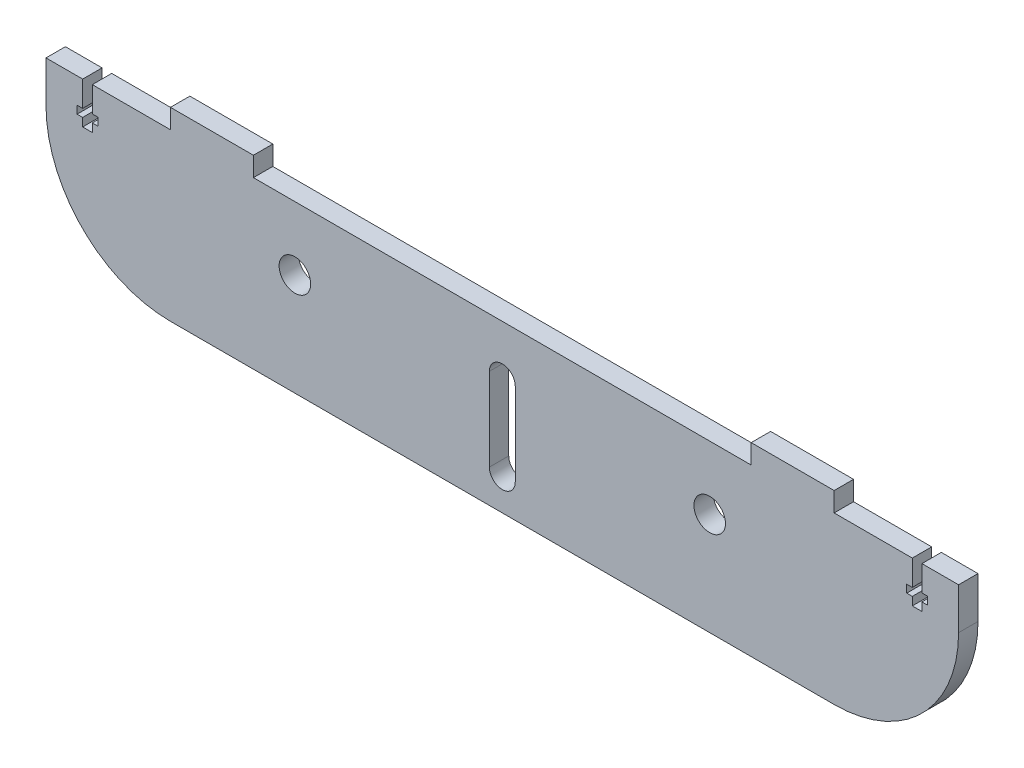
from build123d import *

# Parameters (mm, degrees)
BOSS_EXTRUDE1_DEPTH = 5.9436
CUT_EXTRUDE1_DEPTH  = 6.35
SKETCH3_R           = 4.826
CUT_EXTRUDE2_DEPTH  = 6.9436
CUT_EXTRUDE3_DEPTH  = 6.9436


with BuildPart() as part:
    # Sketch1 → Boss-Extrude1 (new body)
    with BuildSketch(Plane.XY):
        Polygon((-101.6, 25.4), (-101.6, 31.3436), (-76.2, 31.3436), (-76.2, 25.4), (76.2, 25.4), (76.2, 31.3436), (101.6, 31.3436), (101.6, 25.4), (139.7, 25.4), (139.7, -25.4), (-139.7, -25.4), (-139.7, 25.4), align=None)
    extrude(amount=BOSS_EXTRUDE1_DEPTH)

    # Sketch2 → Cut-Extrude1 (cut)
    with BuildSketch(Plane.XY.offset(5.9436)):
        Polygon((-128.4732, 25.4), (-128.4732, 17.62125), (-130.175, 17.62125), (-130.175, 15.24), (-128.4732, 15.24), (-128.4732, 12.7), (-125.5268, 12.7), (-125.5268, 15.24), (-123.825, 15.24), (-123.825, 17.62125), (-125.5268, 17.62125), (-125.5268, 25.4), align=None)
        Polygon((125.5268, 17.62125), (125.5268, 25.4), (128.4732, 25.4), (128.4732, 17.62125), (130.175, 17.62125), (130.175, 15.24), (128.4732, 15.24), (128.4732, 12.7), (125.5268, 12.7), (125.5268, 15.24), (123.825, 15.24), (123.825, 17.62125), align=None)
    extrude(amount=-CUT_EXTRUDE1_DEPTH, mode=Mode.SUBTRACT)

    # Sketch3 → Cut-Extrude2 (cut, through all)
    with BuildSketch(Plane(origin=(0, 0, 0), x_dir=(-1, 0, 0), z_dir=(0, 0, -1))):
        with Locations((-63.5, 5.9436)):
            Circle(SKETCH3_R)
        with Locations((63.5, 5.9436)):
            Circle(SKETCH3_R)
        with BuildLine():
            Line((3.96875, 10.16), (3.96875, -15.24))
            ThreePointArc((3.96875, -15.24), (0, -19.20875), (-3.96875, -15.24))
            Line((-3.96875, -15.24), (-3.96875, 10.16))
            ThreePointArc((-3.96875, 10.16), (0, 14.12875), (3.96875, 10.16))
        make_face()
    extrude(amount=-CUT_EXTRUDE2_DEPTH, mode=Mode.SUBTRACT)

    # Sketch4 → Cut-Extrude3 (cut, through all)
    with BuildSketch(Plane.XY.offset(5.9436)):
        with BuildLine():
            Line((-139.7, 12.7), (-139.7, -25.4))
            Line((-139.7, -25.4), (-101.6, -25.4))
            ThreePointArc((-101.6, -25.4), (-128.540768363, -14.240768363), (-139.7, 12.7))
        make_face()
        with BuildLine():
            Line((139.7, -25.4), (101.6, -25.4))
            ThreePointArc((101.6, -25.4), (128.540768363, -14.240768363), (139.7, 12.7))
            Line((139.7, 12.7), (139.7, -25.4))
        make_face()
    extrude(amount=-CUT_EXTRUDE3_DEPTH, mode=Mode.SUBTRACT)


solid = part.part
